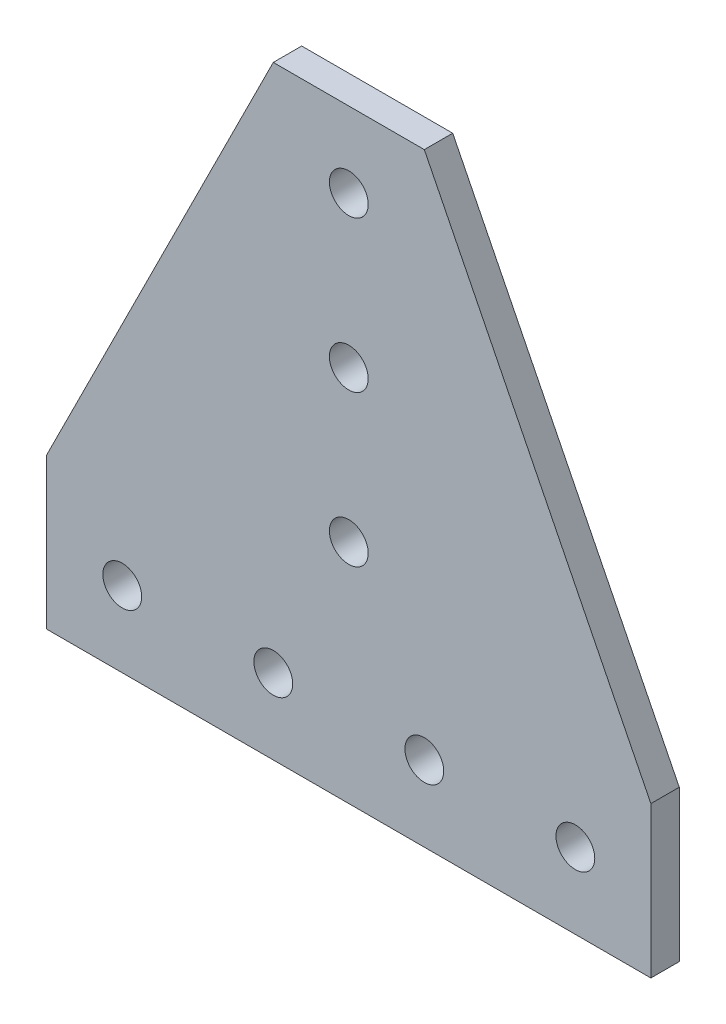
from build123d import *

# Parameters (mm, degrees)
BOSS_EXTRUDE1_DEPTH      = 2.3876
BOSS_EXTRUDE1_DEPTH_BACK = 2.3876
SKETCH4_R                = 3.2639
CUT_EXTRUDE1_DEPTH       = 5.7752


with BuildPart() as part:
    # Sketch3 → Boss-Extrude1 (new body, two sides)
    with BuildSketch(Plane.XY) as boss_extrude1_sk:
        Polygon((50.8, -50.8), (-50.8, -50.8), (-50.8, -25.4), (-12.7, 50.8), (12.7, 50.8), (50.8, -25.4), align=None)
    extrude(amount=BOSS_EXTRUDE1_DEPTH)
    extrude(boss_extrude1_sk.sketch, amount=-BOSS_EXTRUDE1_DEPTH_BACK)

    # Sketch4 → Cut-Extrude1 (cut, through all)
    with BuildSketch(Plane.XY.offset(2.3876)):
        with Locations((-38.1, -38.1)):
            Circle(SKETCH4_R)
        with Locations((-12.7, -38.1)):
            Circle(SKETCH4_R)
        with Locations((12.7, -38.1)):
            Circle(SKETCH4_R)
        with Locations((0, 38.1)):
            Circle(SKETCH4_R)
        with Locations((0, 12.7)):
            Circle(SKETCH4_R)
        with Locations((38.1, -38.1)):
            Circle(SKETCH4_R)
        with Locations((0, -12.7)):
            Circle(SKETCH4_R)
    extrude(amount=-CUT_EXTRUDE1_DEPTH, mode=Mode.SUBTRACT)


solid = part.part
